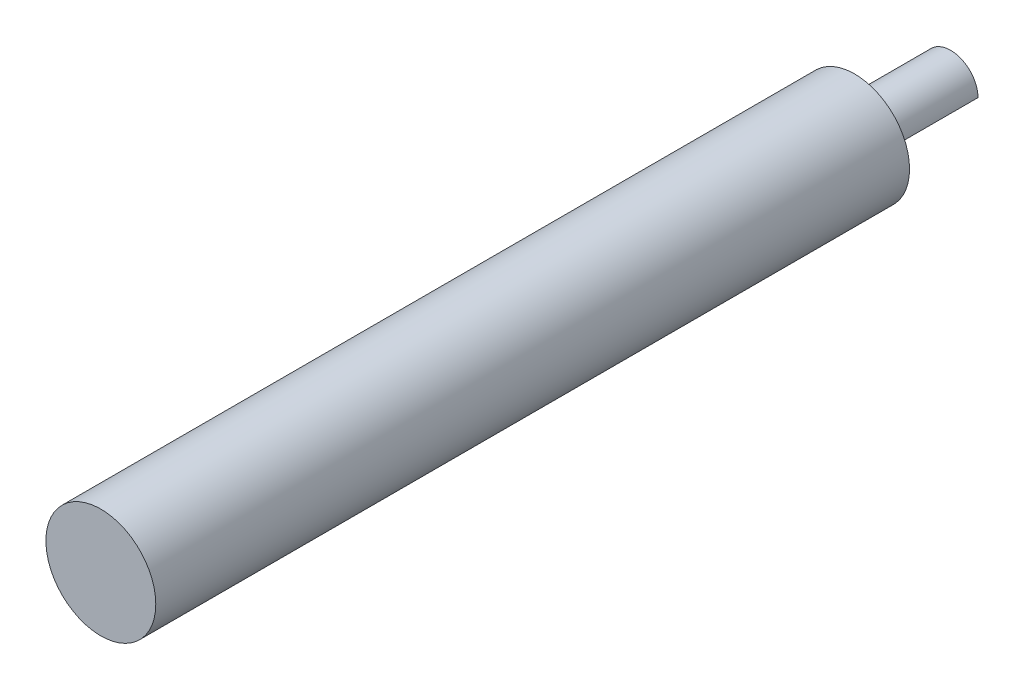
from build123d import *

# Parameters (mm, degrees)
SKETCH1_R               = 3.1623
BOSS_EXTRUDE1_DEPTH     = 11.0998
CUT_EXTRUDE1_DEPTH      = 1
CUT_EXTRUDE1_DEPTH_BACK = 12.0998
SKETCH3_R               = 6.35
BOSS_EXTRUDE2_DEPTH     = 87.122


with BuildPart() as part:
    # Sketch1 → Boss-Extrude1 (new body)
    with BuildSketch(Plane.XY):
        Circle(SKETCH1_R)
    extrude(amount=BOSS_EXTRUDE1_DEPTH)

    # Sketch2 → Cut-Extrude1 (cut, two sides)
    with BuildSketch(Plane(origin=(0, 0, 0), x_dir=(-1, 0, 0), z_dir=(0, 0, -1))) as cut_extrude1_sk:
        Polygon((17.073178183, -20.234228338), (0.001249598, -3.162299753), (-3.162299753, 0.001249598), (-20.234228338, 17.073178183), (-54.378085507, -17.070678986), (-17.070678986, -54.378085507), align=None)
    extrude(amount=CUT_EXTRUDE1_DEPTH, mode=Mode.SUBTRACT)
    extrude(cut_extrude1_sk.sketch, amount=-CUT_EXTRUDE1_DEPTH_BACK, mode=Mode.SUBTRACT)

    # Sketch3 → Boss-Extrude2 (add)
    with BuildSketch(Plane.XY.offset(11.0998)):
        Circle(SKETCH3_R)
    extrude(amount=BOSS_EXTRUDE2_DEPTH)


solid = part.part
